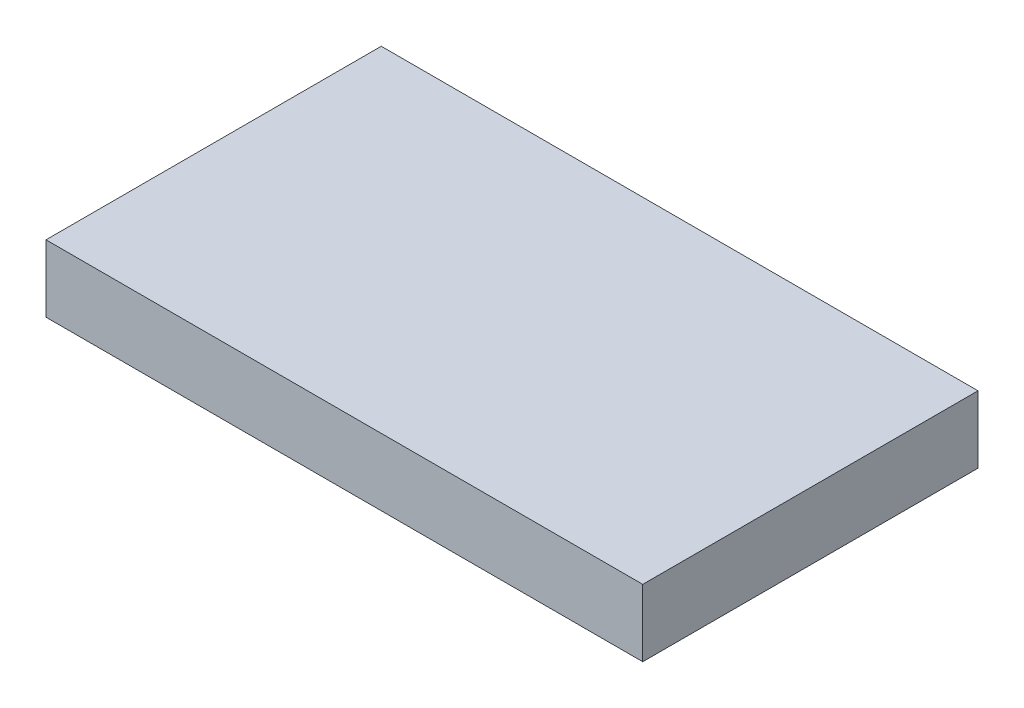
from build123d import *

# Parameters (mm, degrees)
SKETCH_1_W          = 180
SKETCH_1_H          = 100
EXTRUDE_2_DEPTH     = 20
SKETCH_4_W          = 100
SKETCH_4_H          = 20
CUT_EXTRUDE_3_DEPTH = 2


with BuildPart() as part:
    # 草图1 → 凸台-拉伸2 (new body)
    with BuildSketch(Plane(origin=(0, 0, 0), x_dir=(1, 0, 0), z_dir=(0, 1, 0))):
        with Locations((90, 50)):
            Rectangle(SKETCH_1_W, SKETCH_1_H)
    extrude(amount=EXTRUDE_2_DEPTH)

    # 草图4 → 切除-拉伸3 (cut)
    with BuildSketch(Plane(origin=(180, 0, 0), x_dir=(0, 0, -1), z_dir=(1, 0, 0))):
        with Locations((50, 10)):
            Rectangle(SKETCH_4_W, SKETCH_4_H)
    extrude(amount=-CUT_EXTRUDE_3_DEPTH, mode=Mode.SUBTRACT)


solid = part.part
